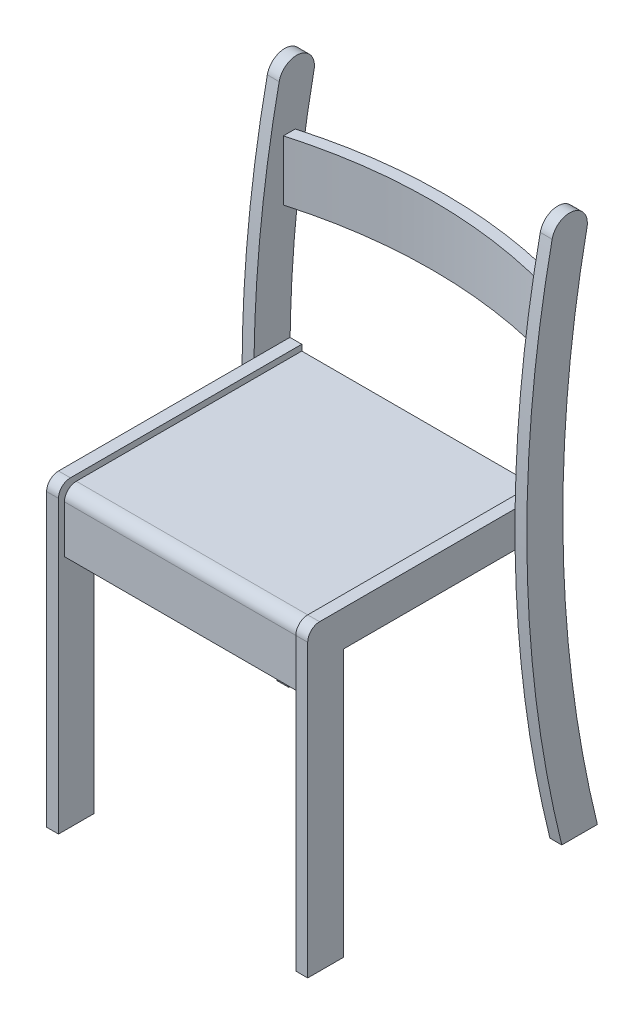
from build123d import *

# Parameters (mm, degrees)
SKETCH1_W                = 400
SKETCH1_H                = 400
BOSS_EXTRUDE1_DEPTH      = 20
SKETCH2_W                = 400
SKETCH2_H                = 20
BOSS_EXTRUDE2_DEPTH      = 80
FILLET1_R                = 20
BOSS_EXTRUDE4_START      = 200
BOSS_EXTRUDE4_DEPTH      = 20
BOSS_EXTRUDE5_START      = -200
BOSS_EXTRUDE5_DEPTH      = 20
FILLET2_R                = 20
BOSS_EXTRUDE6_START      = 220
BOSS_EXTRUDE6_DEPTH      = 20
BOSS_EXTRUDE7_START      = -220
BOSS_EXTRUDE7_DEPTH      = 20
BOSS_EXTRUDE8_START      = 230
BOSS_EXTRUDE8_DEPTH      = 100
BOSS_EXTRUDE8_DEPTH_BACK = 1


with BuildPart() as part:
    # Sketch1 → Boss-Extrude1 (new body)
    with BuildSketch(Plane(origin=(0, 0, 0), x_dir=(1, 0, 0), z_dir=(0, 1, 0))):
        Rectangle(SKETCH1_W, SKETCH1_H)
    extrude(amount=BOSS_EXTRUDE1_DEPTH)

    # Sketch2 → Boss-Extrude2 (add)
    with BuildSketch(Plane.XZ):
        with Locations((0, 190)):
            Rectangle(SKETCH2_W, SKETCH2_H)
    extrude(amount=BOSS_EXTRUDE2_DEPTH)

    # Fillet1
    fillet1_edges = [part.edges().sort_by_distance(p)[0] for p in [
        (0, 20, 200),
    ]]
    fillet(fillet1_edges, radius=FILLET1_R)

    # Sketch3 → Boss-Extrude4 (add)
    with BuildSketch(Plane(origin=(0, 0, 0), x_dir=(0, 0, -1), z_dir=(1, 0, 0)).offset(BOSS_EXTRUDE4_START)):
        Polygon((-210, 30), (-210, -480), (-150, -480), (-150, -30), (200, -30), (200, 30), align=None)
    extrude(amount=BOSS_EXTRUDE4_DEPTH)

    # Sketch3_2 → Boss-Extrude5 (add)
    with BuildSketch(Plane(origin=(0, 0, 0), x_dir=(0, 0, -1), z_dir=(1, 0, 0)).offset(BOSS_EXTRUDE5_START)):
        Polygon((-210, 30), (-210, -480), (-150, -480), (-150, -30), (200, -30), (200, 30), align=None)
    extrude(amount=-BOSS_EXTRUDE5_DEPTH)

    # Fillet2
    fillet2_edges = [part.edges().sort_by_distance(p)[0] for p in [
        (210, 30, 210),
        (-210, 30, 210),
    ]]
    fillet(fillet2_edges, radius=FILLET2_R)

    # Sketch4 → Boss-Extrude6 (add)
    with BuildSketch(Plane(origin=(0, 0, 0), x_dir=(0, 0, -1), z_dir=(1, 0, 0)).offset(BOSS_EXTRUDE6_START)):
        with BuildLine():
            Line((258.164028918, -480), (198.164028918, -480))
            ThreePointArc((198.164028918, -480), (139.643388702, -34.801550566), (181.919205568, 412.23209472))
            ThreePointArc((181.919205568, 412.23209472), (217.850685316, 435.347336903), (240.463992613, 399.097868063))
            ThreePointArc((240.463992613, 399.097868063), (200.405267559, -41.435810173), (258.164028918, -480))
        make_face()
    extrude(amount=BOSS_EXTRUDE6_DEPTH)

    # Sketch4_2 → Boss-Extrude7 (add)
    with BuildSketch(Plane(origin=(0, 0, 0), x_dir=(0, 0, -1), z_dir=(1, 0, 0)).offset(BOSS_EXTRUDE7_START)):
        with BuildLine():
            Line((258.164028918, -480), (198.164028918, -480))
            ThreePointArc((198.164028918, -480), (139.643388702, -34.801550566), (181.919205568, 412.23209472))
            ThreePointArc((181.919205568, 412.23209472), (217.850685316, 435.347336903), (240.463992613, 399.097868063))
            ThreePointArc((240.463992613, 399.097868063), (200.405267559, -41.435810173), (258.164028918, -480))
        make_face()
    extrude(amount=-BOSS_EXTRUDE7_DEPTH)

    # Sketch7 → Boss-Extrude8 (add, two sides)
    with BuildSketch(Plane(origin=(0, 0, 0), x_dir=(1, 0, 0), z_dir=(0, 1, 0)).offset(BOSS_EXTRUDE8_START)) as boss_extrude8_sk:
        with BuildLine():
            Line((-219.629521945, 188.607337024), (-219.629521945, 208.607337024))
            ThreePointArc((-219.629521945, 208.607337024), (0.370478055, 239.451956103), (220.370478055, 208.607337024))
            Line((220.370478055, 208.607337024), (220.370478055, 188.607337024))
            ThreePointArc((220.370478055, 188.607337024), (0.370478055, 219.451956103), (-219.629521945, 188.607337024))
        make_face()
    extrude(amount=BOSS_EXTRUDE8_DEPTH)
    extrude(boss_extrude8_sk.sketch, amount=-BOSS_EXTRUDE8_DEPTH_BACK)


solid = part.part
